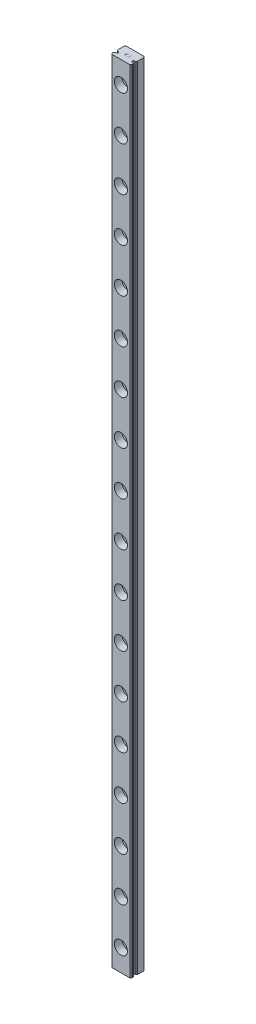
from build123d import *

# Parameters (mm, degrees)
SALIENTE_EXTRUIR1_DEPTH               = 360
CORTAR_EXTRUIR1_DEPTH                 = 361.086795093
CORTAR_EXTRUIR2_DEPTH                 = 361.086795093
CORTAR_EXTRUIR3_DEPTH                 = 361.086795093
CORTAR_EXTRUIR4_DEPTH                 = 361.086795093
CORTAR_EXTRUIR5_DEPTH                 = 361.086795093
CORTAR_EXTRUIR6_DEPTH                 = 361.086795093
CORTAR_EXTRUIR7_DEPTH                 = 0.002166667
CORTAR_EXTRUIR8_DEPTH                 = 0.002166667
CORTAR_EXTRUIR9_DEPTH                 = 0.002166667
CORTAR_EXTRUIR10_DEPTH                = 0.002166667
NGULO_DE_SALIDA1_ANGLE                = 45.1469538
TALADRO_ROSCADO_M3_5X0_61_AT_2_COUNT  = 2
TALADRO_ROSCADO_M3_5X0_61_AT_2_PITCH  = 20
TALADRO_ROSCADO_M3_5X0_61_AT_3_COUNT  = 2
TALADRO_ROSCADO_M3_5X0_61_AT_3_PITCH  = 40
TALADRO_ROSCADO_M3_5X0_61_AT_4_COUNT  = 2
TALADRO_ROSCADO_M3_5X0_61_AT_4_PITCH  = 60
TALADRO_ROSCADO_M3_5X0_61_AT_5_COUNT  = 2
TALADRO_ROSCADO_M3_5X0_61_AT_5_PITCH  = 80
TALADRO_ROSCADO_M3_5X0_61_AT_6_COUNT  = 2
TALADRO_ROSCADO_M3_5X0_61_AT_6_PITCH  = 100
TALADRO_ROSCADO_M3_5X0_61_AT_7_COUNT  = 2
TALADRO_ROSCADO_M3_5X0_61_AT_7_PITCH  = 120
TALADRO_ROSCADO_M3_5X0_61_AT_8_COUNT  = 2
TALADRO_ROSCADO_M3_5X0_61_AT_8_PITCH  = 140
TALADRO_ROSCADO_M3_5X0_61_AT_9_COUNT  = 2
TALADRO_ROSCADO_M3_5X0_61_AT_9_PITCH  = 160
TALADRO_ROSCADO_M3_5X0_61_AT_10_COUNT = 2
TALADRO_ROSCADO_M3_5X0_61_AT_10_PITCH = 180
TALADRO_ROSCADO_M3_5X0_61_AT_11_COUNT = 2
TALADRO_ROSCADO_M3_5X0_61_AT_11_PITCH = 200
TALADRO_ROSCADO_M3_5X0_61_AT_12_COUNT = 2
TALADRO_ROSCADO_M3_5X0_61_AT_12_PITCH = 220
TALADRO_ROSCADO_M3_5X0_61_AT_13_COUNT = 2
TALADRO_ROSCADO_M3_5X0_61_AT_13_PITCH = 240
TALADRO_ROSCADO_M3_5X0_61_AT_14_COUNT = 2
TALADRO_ROSCADO_M3_5X0_61_AT_14_PITCH = 260
TALADRO_ROSCADO_M3_5X0_61_AT_15_COUNT = 2
TALADRO_ROSCADO_M3_5X0_61_AT_15_PITCH = 280
TALADRO_ROSCADO_M3_5X0_61_AT_16_COUNT = 2
TALADRO_ROSCADO_M3_5X0_61_AT_16_PITCH = 300
TALADRO_ROSCADO_M3_5X0_61_AT_17_COUNT = 2
TALADRO_ROSCADO_M3_5X0_61_AT_17_PITCH = 320
TALADRO_ROSCADO_M3_5X0_61_AT_18_COUNT = 2
TALADRO_ROSCADO_M3_5X0_61_AT_18_PITCH = 20
CHAFL_N1_SIZE                         = 0.4
REDONDEO1_R                           = 0.130000023
SKETCH1_R                             = 3
CUT_EXTRUDE1_DEPTH                    = 3


with BuildPart() as part:
    # Croquis1 → Saliente-Extruir1 (new body)
    with BuildSketch(Plane.XZ):
        Polygon((4.5, 0), (4.5, 6.01167813), (4.1, 6.50000002), (-4.1, 6.50000002), (-4.5, 6.01167813), (-4.5, 0), align=None)
    extrude(amount=-SALIENTE_EXTRUIR1_DEPTH)

    # Croquis2 → Cortar-Extruir1 (cut, through all)
    with BuildSketch(Plane(origin=(0, 360, 0), x_dir=(-1, 0, 0), z_dir=(0, 1, 0))):
        with BuildLine():
            Line((-4.5, 4.88017535), (-4.5, 4.03150278))
            Line((-4.5, 4.03150278), (-3.819258765, 4.03150278))
            ThreePointArc((-3.819258765, 4.03150278), (-3.21946318, 4.455839065), (-3.819258765, 4.88017535))
            Line((-3.819258765, 4.88017535), (-4.5, 4.88017535))
        make_face()
    extrude(amount=-CORTAR_EXTRUIR1_DEPTH, mode=Mode.SUBTRACT)

    # Croquis3 → Cortar-Extruir2 (cut, through all)
    with BuildSketch(Plane(origin=(0, 360, 0), x_dir=(-1, 0, 0), z_dir=(0, 1, 0))):
        with BuildLine():
            Line((-4.026513856, 4.03150278), (-4.5, 4.03150278))
            Line((-4.5, 4.03150278), (-4.5, 3.583620931))
            ThreePointArc((-4.5, 3.583620931), (-4.223645982, 3.76568645), (-4.026513856, 4.03150278))
        make_face()
    extrude(amount=-CORTAR_EXTRUIR2_DEPTH, mode=Mode.SUBTRACT)

    # Croquis4 → Cortar-Extruir3 (cut, through all)
    with BuildSketch(Plane(origin=(0, 360, 0), x_dir=(-1, 0, 0), z_dir=(0, 1, 0))):
        with BuildLine():
            Line((-4.5, 5.328056964), (-4.5, 4.88017535))
            Line((-4.5, 4.88017535), (-4.026513974, 4.88017535))
            ThreePointArc((-4.026513974, 4.88017535), (-4.223646078, 5.145991535), (-4.5, 5.328056964))
        make_face()
    extrude(amount=-CORTAR_EXTRUIR3_DEPTH, mode=Mode.SUBTRACT)

    # Croquis5 → Cortar-Extruir4 (cut, through all)
    with BuildSketch(Plane(origin=(0, 360, 0), x_dir=(-1, 0, 0), z_dir=(0, 1, 0))):
        with BuildLine():
            Line((4.5, 4.03150278), (4.5, 4.88017535))
            Line((4.5, 4.88017535), (3.819258765, 4.88017535))
            ThreePointArc((3.819258765, 4.88017535), (3.21946318, 4.455839065), (3.819258765, 4.03150278))
            Line((3.819258765, 4.03150278), (4.5, 4.03150278))
        make_face()
    extrude(amount=-CORTAR_EXTRUIR4_DEPTH, mode=Mode.SUBTRACT)

    # Croquis6 → Cortar-Extruir5 (cut, through all)
    with BuildSketch(Plane(origin=(0, 360, 0), x_dir=(-1, 0, 0), z_dir=(0, 1, 0))):
        with BuildLine():
            Line((4.026513826, 4.88017535), (4.5, 4.88017535))
            Line((4.5, 4.88017535), (4.5, 5.328057255))
            ThreePointArc((4.5, 5.328057255), (4.223645966, 5.145991706), (4.026513826, 4.88017535))
        make_face()
    extrude(amount=-CORTAR_EXTRUIR5_DEPTH, mode=Mode.SUBTRACT)

    # Croquis7 → Cortar-Extruir6 (cut, through all)
    with BuildSketch(Plane(origin=(0, 360, 0), x_dir=(-1, 0, 0), z_dir=(0, 1, 0))):
        with BuildLine():
            Line((4.5, 3.583620926), (4.5, 4.03150278))
            Line((4.5, 4.03150278), (4.026513851, 4.03150278))
            ThreePointArc((4.026513851, 4.03150278), (4.223645987, 3.765686455), (4.5, 3.583620926))
        make_face()
    extrude(amount=-CORTAR_EXTRUIR6_DEPTH, mode=Mode.SUBTRACT)

    # Croquis8 → Cortar-Extruir7 (cut)
    with BuildSketch(Plane(origin=(0, 360, 0), x_dir=(-1, 0, 0), z_dir=(0, 1, 0))):
        Polygon((0.891369267, 3.403698133), (0.714701433, 3.168235633), (0.2187042, 2.61105), (1.0945792, 2.61105), (1.0945792, 2.695983333), (0.398689633, 2.695983333), (0.794326433, 3.149466667), (0.9743123, 3.3891), (1.067110588, 3.573407857), (0.95413722, 3.802321701), (0.7876908, 3.88505), (0.54301, 3.88505), (0.375434678, 3.803592619), (0.295011167, 3.6384023), (0.295011167, 3.562), (0.3812718, 3.562), (0.3812718, 3.631766667), (0.437672733, 3.743620833), (0.549645633, 3.800116667), (0.7802262, 3.800116667), (0.893028067, 3.743810633), (0.976240026, 3.576039029), align=None)
    extrude(amount=-CORTAR_EXTRUIR7_DEPTH, mode=Mode.SUBTRACT)

    # Croquis9 → Cortar-Extruir8 (cut)
    with BuildSketch(Plane.XZ):
        Polygon((-0.214632167, 3.88505), (-0.953983333, 3.88505), (-0.953983333, 2.61105), (-0.214632167, 2.61105), (-0.214632167, 2.695983333), (-0.86905, 2.695983333), (-0.86905, 3.205583333), (-0.5123963, 3.205583333), (-0.5123963, 3.290516667), (-0.86905, 3.290516667), (-0.86905, 3.800116667), (-0.214632167, 3.800116667), align=None)
    extrude(amount=-CORTAR_EXTRUIR8_DEPTH, mode=Mode.SUBTRACT)

    # Croquis10 → Cortar-Extruir9 (cut)
    with BuildSketch(Plane(origin=(0, 360, 0), x_dir=(-1, 0, 0), z_dir=(0, 1, 0))):
        Polygon((-0.214632167, 3.88505), (-0.953983333, 3.88505), (-0.953983333, 2.61105), (-0.214632167, 2.61105), (-0.214632167, 2.695983333), (-0.86905, 2.695983333), (-0.86905, 3.205583333), (-0.5123963, 3.205583333), (-0.5123963, 3.290516667), (-0.86905, 3.290516667), (-0.86905, 3.800116667), (-0.214632167, 3.800116667), align=None)
    extrude(amount=-CORTAR_EXTRUIR9_DEPTH, mode=Mode.SUBTRACT)

    # Croquis11 → Cortar-Extruir10 (cut)
    with BuildSketch(Plane.XZ):
        Polygon((0.510057167, 3.620830633), (0.6071, 3.718655633), (0.6071, 2.609403333), (0.692033333, 2.609403333), (0.692033333, 3.883403333), (0.6741176, 3.883403333), (0.6741176, 3.795069794), (0.3690544, 3.640736667), (0.3690544, 3.551253333), align=None)
    extrude(amount=-CORTAR_EXTRUIR10_DEPTH, mode=Mode.SUBTRACT)

    # Ángulo de salida1
    ngulo_de_salida1_faces = [part.faces().sort_by_distance(p)[0] for p in [
        (0.6741176, 0.001083333, 3.839236564),
    ]]
    draft(ngulo_de_salida1_faces, Plane(origin=(0.692033333, 0.002166667, 3.883403333), x_dir=(-1, 0, 0), z_dir=(0, 0, -1)), NGULO_DE_SALIDA1_ANGLE)

    # Croquis34 → Taladro roscado M3.5x0.61 (revolve, cut)
    with BuildSketch(Plane(origin=(0, 330, 0), x_dir=(0, 1, 0), z_dir=(1, 0, 0))):
        Polygon((0, 0), (0, 6.09), (3, 6.09), (3, 3), (1.75, 3), (1.75, 0), align=None)
    taladro_roscado_m3_5x0_61 = revolve(axis=Axis((0, 330, -6.35), (0, 0, 1)), mode=Mode.SUBTRACT)

    # Taladro roscado M3.5x0.61 at 2: Taladro roscado M3.5x0.61 ×2
    with Locations(*[(0, -i * TALADRO_ROSCADO_M3_5X0_61_AT_2_PITCH, 0) for i in range(1, TALADRO_ROSCADO_M3_5X0_61_AT_2_COUNT)]):
        add(taladro_roscado_m3_5x0_61, mode=Mode.SUBTRACT)

    # Taladro roscado M3.5x0.61 at 3: Taladro roscado M3.5x0.61 ×2
    with Locations(*[(0, -i * TALADRO_ROSCADO_M3_5X0_61_AT_3_PITCH, 0) for i in range(1, TALADRO_ROSCADO_M3_5X0_61_AT_3_COUNT)]):
        add(taladro_roscado_m3_5x0_61, mode=Mode.SUBTRACT)

    # Taladro roscado M3.5x0.61 at 4: Taladro roscado M3.5x0.61 ×2
    with Locations(*[(0, -i * TALADRO_ROSCADO_M3_5X0_61_AT_4_PITCH, 0) for i in range(1, TALADRO_ROSCADO_M3_5X0_61_AT_4_COUNT)]):
        add(taladro_roscado_m3_5x0_61, mode=Mode.SUBTRACT)

    # Taladro roscado M3.5x0.61 at 5: Taladro roscado M3.5x0.61 ×2
    with Locations(*[(0, -i * TALADRO_ROSCADO_M3_5X0_61_AT_5_PITCH, 0) for i in range(1, TALADRO_ROSCADO_M3_5X0_61_AT_5_COUNT)]):
        add(taladro_roscado_m3_5x0_61, mode=Mode.SUBTRACT)

    # Taladro roscado M3.5x0.61 at 6: Taladro roscado M3.5x0.61 ×2
    with Locations(*[(0, -i * TALADRO_ROSCADO_M3_5X0_61_AT_6_PITCH, 0) for i in range(1, TALADRO_ROSCADO_M3_5X0_61_AT_6_COUNT)]):
        add(taladro_roscado_m3_5x0_61, mode=Mode.SUBTRACT)

    # Taladro roscado M3.5x0.61 at 7: Taladro roscado M3.5x0.61 ×2
    with Locations(*[(0, -i * TALADRO_ROSCADO_M3_5X0_61_AT_7_PITCH, 0) for i in range(1, TALADRO_ROSCADO_M3_5X0_61_AT_7_COUNT)]):
        add(taladro_roscado_m3_5x0_61, mode=Mode.SUBTRACT)

    # Taladro roscado M3.5x0.61 at 8: Taladro roscado M3.5x0.61 ×2
    with Locations(*[(0, -i * TALADRO_ROSCADO_M3_5X0_61_AT_8_PITCH, 0) for i in range(1, TALADRO_ROSCADO_M3_5X0_61_AT_8_COUNT)]):
        add(taladro_roscado_m3_5x0_61, mode=Mode.SUBTRACT)

    # Taladro roscado M3.5x0.61 at 9: Taladro roscado M3.5x0.61 ×2
    with Locations(*[(0, -i * TALADRO_ROSCADO_M3_5X0_61_AT_9_PITCH, 0) for i in range(1, TALADRO_ROSCADO_M3_5X0_61_AT_9_COUNT)]):
        add(taladro_roscado_m3_5x0_61, mode=Mode.SUBTRACT)

    # Taladro roscado M3.5x0.61 at 10: Taladro roscado M3.5x0.61 ×2
    with Locations(*[(0, -i * TALADRO_ROSCADO_M3_5X0_61_AT_10_PITCH, 0) for i in range(1, TALADRO_ROSCADO_M3_5X0_61_AT_10_COUNT)]):
        add(taladro_roscado_m3_5x0_61, mode=Mode.SUBTRACT)

    # Taladro roscado M3.5x0.61 at 11: Taladro roscado M3.5x0.61 ×2
    with Locations(*[(0, -i * TALADRO_ROSCADO_M3_5X0_61_AT_11_PITCH, 0) for i in range(1, TALADRO_ROSCADO_M3_5X0_61_AT_11_COUNT)]):
        add(taladro_roscado_m3_5x0_61, mode=Mode.SUBTRACT)

    # Taladro roscado M3.5x0.61 at 12: Taladro roscado M3.5x0.61 ×2
    with Locations(*[(0, -i * TALADRO_ROSCADO_M3_5X0_61_AT_12_PITCH, 0) for i in range(1, TALADRO_ROSCADO_M3_5X0_61_AT_12_COUNT)]):
        add(taladro_roscado_m3_5x0_61, mode=Mode.SUBTRACT)

    # Taladro roscado M3.5x0.61 at 13: Taladro roscado M3.5x0.61 ×2
    with Locations(*[(0, -i * TALADRO_ROSCADO_M3_5X0_61_AT_13_PITCH, 0) for i in range(1, TALADRO_ROSCADO_M3_5X0_61_AT_13_COUNT)]):
        add(taladro_roscado_m3_5x0_61, mode=Mode.SUBTRACT)

    # Taladro roscado M3.5x0.61 at 14: Taladro roscado M3.5x0.61 ×2
    with Locations(*[(0, -i * TALADRO_ROSCADO_M3_5X0_61_AT_14_PITCH, 0) for i in range(1, TALADRO_ROSCADO_M3_5X0_61_AT_14_COUNT)]):
        add(taladro_roscado_m3_5x0_61, mode=Mode.SUBTRACT)

    # Taladro roscado M3.5x0.61 at 15: Taladro roscado M3.5x0.61 ×2
    with Locations(*[(0, -i * TALADRO_ROSCADO_M3_5X0_61_AT_15_PITCH, 0) for i in range(1, TALADRO_ROSCADO_M3_5X0_61_AT_15_COUNT)]):
        add(taladro_roscado_m3_5x0_61, mode=Mode.SUBTRACT)

    # Taladro roscado M3.5x0.61 at 16: Taladro roscado M3.5x0.61 ×2
    with Locations(*[(0, -i * TALADRO_ROSCADO_M3_5X0_61_AT_16_PITCH, 0) for i in range(1, TALADRO_ROSCADO_M3_5X0_61_AT_16_COUNT)]):
        add(taladro_roscado_m3_5x0_61, mode=Mode.SUBTRACT)

    # Taladro roscado M3.5x0.61 at 17: Taladro roscado M3.5x0.61 ×2
    with Locations(*[(0, -i * TALADRO_ROSCADO_M3_5X0_61_AT_17_PITCH, 0) for i in range(1, TALADRO_ROSCADO_M3_5X0_61_AT_17_COUNT)]):
        add(taladro_roscado_m3_5x0_61, mode=Mode.SUBTRACT)

    # Taladro roscado M3.5x0.61 at 18: Taladro roscado M3.5x0.61 ×2
    with Locations(*[(0, i * TALADRO_ROSCADO_M3_5X0_61_AT_18_PITCH, 0) for i in range(1, TALADRO_ROSCADO_M3_5X0_61_AT_18_COUNT)]):
        add(taladro_roscado_m3_5x0_61, mode=Mode.SUBTRACT)

    # Chaflán1
    chafl_n1_edges = [part.edges().sort_by_distance(p)[0] for p in [
        (-4.5, 180, 0),
        (4.5, 180, 0),
    ]]
    chamfer(chafl_n1_edges, length=CHAFL_N1_SIZE)

    # Redondeo1
    redondeo1_edges = [part.edges().sort_by_distance(p)[0] for p in [
        (4.026513856, 180, 4.03150278),
        (4.5, 180, 3.583620931),
        (4.5, 180, 5.328056964),
        (4.026513974, 180, 4.88017535),
        (-4.026513826, 180, 4.88017535),
        (-4.5, 180, 5.328057255),
        (-4.5, 180, 3.583620926),
        (-4.026513851, 180, 4.03150278),
    ]]
    fillet(redondeo1_edges, radius=REDONDEO1_R)

    # Sketch1 → Cut-Extrude1 (cut)
    with BuildSketch(Plane.XY.offset(6.50000002)):
        with Locations(Location((0, 10, 0), (0, 0, 180))):
            Circle(SKETCH1_R)
        with Locations(Location((0, 30, 0), (0, 0, 180))):
            Circle(SKETCH1_R)
        with Locations(Location((0, 50, 0), (0, 0, 180))):
            Circle(SKETCH1_R)
        with Locations(Location((0, 70, 0), (0, 0, 180))):
            Circle(SKETCH1_R)
        with Locations(Location((0, 90, 0), (0, 0, 180))):
            Circle(SKETCH1_R)
        with Locations(Location((0, 110, 0), (0, 0, 180))):
            Circle(SKETCH1_R)
        with Locations(Location((0, 130, 0), (0, 0, 180))):
            Circle(SKETCH1_R)
        with Locations(Location((0, 150, 0), (0, 0, 180))):
            Circle(SKETCH1_R)
        with Locations(Location((0, 170, 0), (0, 0, 180))):
            Circle(SKETCH1_R)
        with Locations(Location((0, 190, 0), (0, 0, 180))):
            Circle(SKETCH1_R)
        with Locations(Location((0, 210, 0), (0, 0, 180))):
            Circle(SKETCH1_R)
        with Locations(Location((0, 230, 0), (0, 0, 180))):
            Circle(SKETCH1_R)
        with Locations(Location((0, 250, 0), (0, 0, 180))):
            Circle(SKETCH1_R)
        with Locations(Location((0, 270, 0), (0, 0, 180))):
            Circle(SKETCH1_R)
        with Locations(Location((0, 290, 0), (0, 0, 180))):
            Circle(SKETCH1_R)
        with Locations(Location((0, 310, 0), (0, 0, 180))):
            Circle(SKETCH1_R)
        with Locations(Location((0, 330, 0), (0, 0, 180))):
            Circle(SKETCH1_R)
        with Locations(Location((0, 350, 0), (0, 0, 180))):
            Circle(SKETCH1_R)
    extrude(amount=-CUT_EXTRUDE1_DEPTH, mode=Mode.SUBTRACT)


solid = part.part
